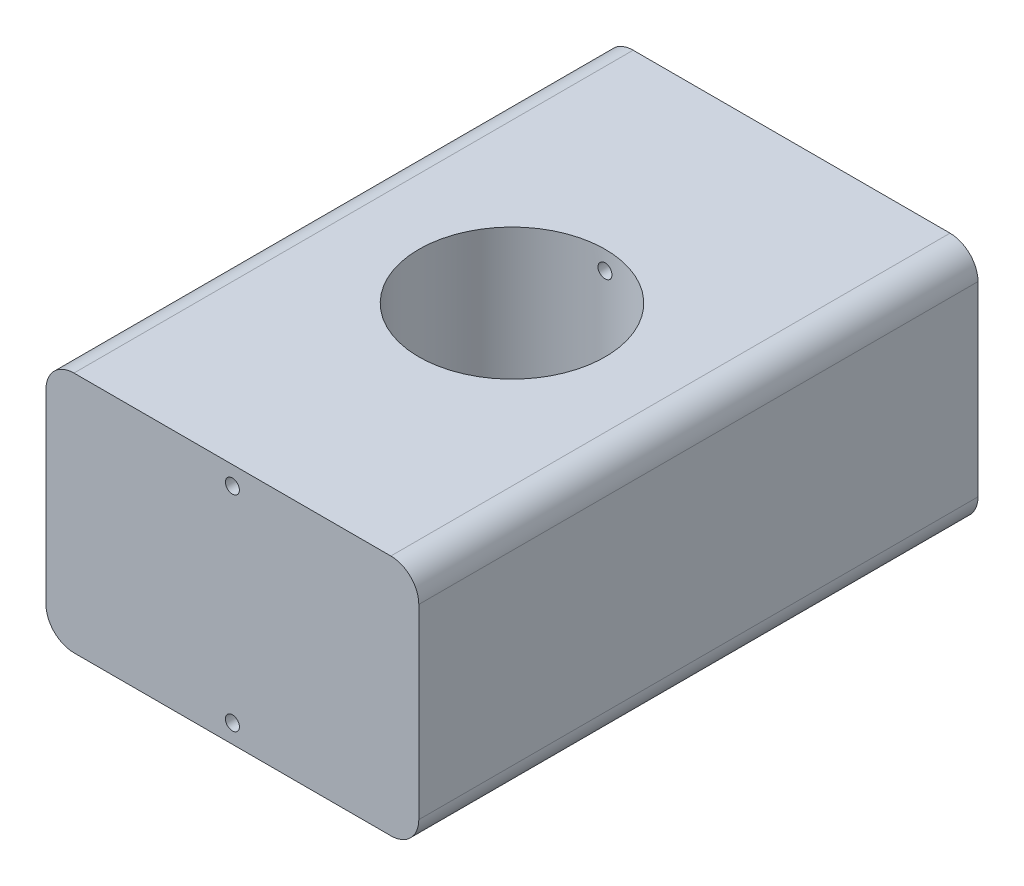
from build123d import *

# Parameters (mm, degrees)
SKETCH1_W           = 40
SKETCH1_H           = 26
SKETCH1_R           = 0.75
BOSS_EXTRUDE1_DEPTH = 60
FILLET1_R           = 3
FILLET2_R           = 3
SKETCH2_R           = 10
CUT_EXTRUDE1_DEPTH  = 27


with BuildPart() as part:
    # Sketch1 → Boss-Extrude1 (new body)
    with BuildSketch(Plane.XY):
        Rectangle(SKETCH1_W, SKETCH1_H)
        with Locations((0, 11)):
            Circle(SKETCH1_R, mode=Mode.SUBTRACT)
        with Locations((0, -11)):
            Circle(SKETCH1_R, mode=Mode.SUBTRACT)
    extrude(amount=BOSS_EXTRUDE1_DEPTH)

    # Fillet1
    fillet1_edges = [part.edges().sort_by_distance(p)[0] for p in [
        (20, 13, 30),
    ]]
    fillet(fillet1_edges, radius=FILLET1_R)

    # Fillet2
    fillet2_edges = [part.edges().sort_by_distance(p)[0] for p in [
        (20, -13, 30),
        (-20, -13, 30),
        (-20, 13, 30),
    ]]
    fillet(fillet2_edges, radius=FILLET2_R)

    # Sketch2 → Cut-Extrude1 (cut, through all)
    with BuildSketch(Plane(origin=(0, 13, 0), x_dir=(1, 0, 0), z_dir=(0, 1, 0))):
        with Locations((0, -30)):
            Circle(SKETCH2_R)
    extrude(amount=-CUT_EXTRUDE1_DEPTH, mode=Mode.SUBTRACT)


solid = part.part
